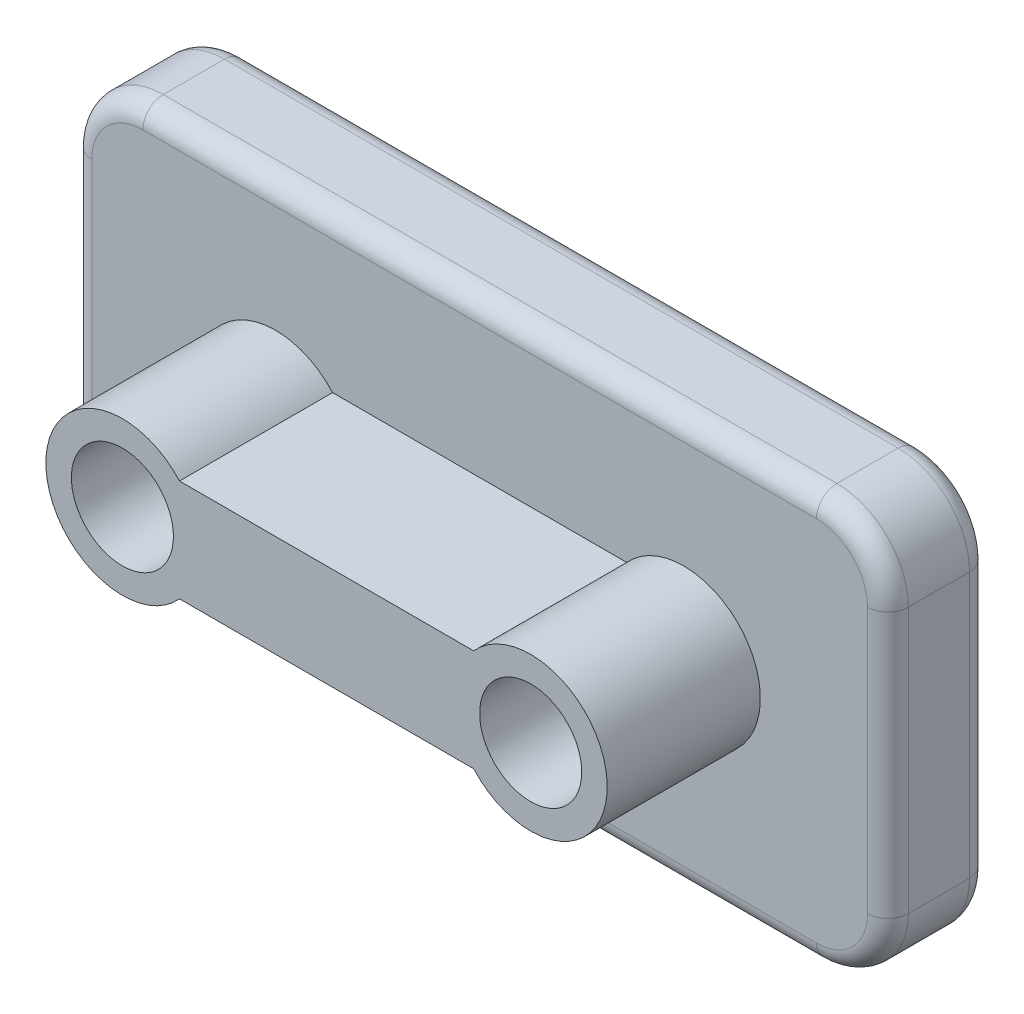
from build123d import *

# Parameters (mm, degrees)
BOSS_EXTRUDE1_DEPTH = 10
FILLET1_R           = 2
FILLET2_R           = 2
SKETCH2_R           = 7.5
BOSS_EXTRUDE3_DEPTH = 15
SKETCH3_R           = 5
CUT_EXTRUDE1_DEPTH  = 15
SKETCH4_R           = 5
CUT_EXTRUDE2_DEPTH  = 15
RIB1_REACH          = 94.871
SKETCH5_WALLS_W     = 202.74175621
SKETCH5_WALLS_H     = 10


with BuildPart() as part:
    # Sketch1 → Boss-Extrude1 (new body)
    with BuildSketch(Plane.XY):
        with BuildLine():
            Line((7, 0), (73, 0))
            ThreePointArc((73, 0), (77.949747468, 2.050252532), (80, 7))
            Line((80, 7), (80, 33))
            ThreePointArc((80, 33), (77.949747468, 37.949747468), (73, 40))
            Line((73, 40), (7, 40))
            ThreePointArc((7, 40), (2.050252532, 37.949747468), (0, 33))
            Line((0, 33), (0, 7))
            ThreePointArc((0, 7), (2.050252532, 2.050252532), (7, 0))
        make_face()
    extrude(amount=BOSS_EXTRUDE1_DEPTH)

    # Fillet1
    fillet1_edges = [part.edges().sort_by_distance(p)[0] for p in [
        (40, 40, 0),
        (2.050252532, 37.949747468, 0),
        (0, 20, 0),
        (2.050252532, 2.050252532, 0),
        (40, 0, 0),
        (77.949747468, 2.050252532, 0),
        (80, 20, 0),
        (77.949747468, 37.949747468, 0),
    ]]
    fillet(fillet1_edges, radius=FILLET1_R)

    # Fillet2
    fillet2_edges = [part.edges().sort_by_distance(p)[0] for p in [
        (2.050252532, 37.949747468, 10),
        (40, 40, 10),
        (77.949747468, 37.949747468, 10),
        (80, 20, 10),
        (77.949747468, 2.050252532, 10),
        (40, 0, 10),
        (2.050252532, 2.050252532, 10),
        (0, 20, 10),
    ]]
    fillet(fillet2_edges, radius=FILLET2_R)

    # Sketch2 → Boss-Extrude3 (add)
    with BuildSketch(Plane.XY.offset(10)):
        with Locations(Location((20, 20, 0), (0, 0, 180))):
            Circle(SKETCH2_R)
        with Locations(Location((60, 20, 0), (0, 0, 180))):
            Circle(SKETCH2_R)
    extrude(amount=BOSS_EXTRUDE3_DEPTH)

    # Sketch3 → Cut-Extrude1 (cut)
    with BuildSketch(Plane.XY.offset(25)):
        with Locations((20, 20)):
            Circle(SKETCH3_R)
    extrude(amount=-CUT_EXTRUDE1_DEPTH, mode=Mode.SUBTRACT)

    # Sketch4 → Cut-Extrude2 (cut)
    with BuildSketch(Plane.XY.offset(25)):
        with Locations((60, 20)):
            Circle(SKETCH4_R)
    extrude(amount=-CUT_EXTRUDE2_DEPTH, mode=Mode.SUBTRACT)

    # Sketch5 walls → Rib1 (add, up to next)
    with BuildSketch(Plane.XY.offset(25), mode=Mode.PRIVATE) as rib1_sk1:
        with Locations((40.936137708, 20)):
            Rectangle(SKETCH5_WALLS_W, SKETCH5_WALLS_H)
    rib1_tool1 = extrude(rib1_sk1.sketch, amount=-RIB1_REACH, mode=Mode.PRIVATE) - part.part
    add(rib1_tool1.solids().sort_by_distance((40.936137708, 20, 25))[0])


solid = part.part
